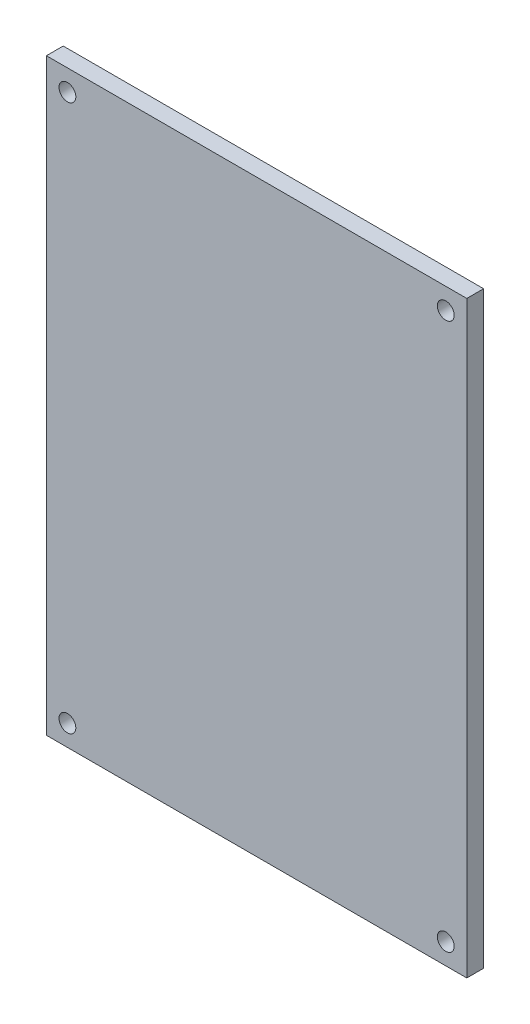
from build123d import *

# Parameters (mm, degrees)
SKETCH_1_W      = 50
SKETCH_1_H      = 70
SKETCH_1_R      = 1
EXTRUDE_1_DEPTH = 2


with BuildPart() as part:
    # 草图1 → 凸台-拉伸1 (new body)
    with BuildSketch(Plane.XY):
        Rectangle(SKETCH_1_W, SKETCH_1_H)
        with Locations((-22.5, 32.5)):
            Circle(SKETCH_1_R, mode=Mode.SUBTRACT)
        with Locations((22.5, 32.5)):
            Circle(SKETCH_1_R, mode=Mode.SUBTRACT)
        with Locations((22.5, -32.5)):
            Circle(SKETCH_1_R, mode=Mode.SUBTRACT)
        with Locations((-22.5, -32.5)):
            Circle(SKETCH_1_R, mode=Mode.SUBTRACT)
    extrude(amount=EXTRUDE_1_DEPTH)


solid = part.part
